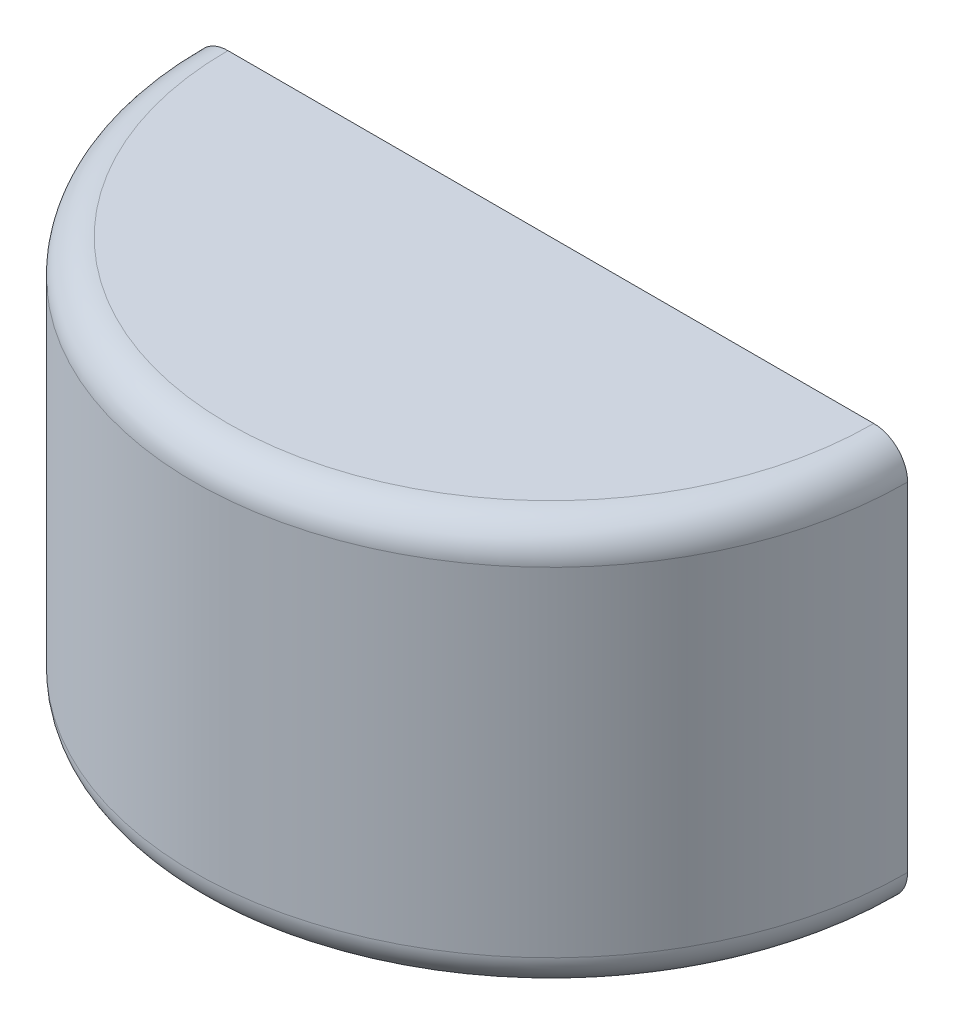
from build123d import *

# Parameters (mm, degrees)
SKETCH1_W      = 133.985
SKETCH1_H      = 152.4
REVOLVE1_ANGLE = 180
FILLET1_R      = 12.7


with BuildPart() as part:
    # Sketch1 → Revolve1 (revolve)
    with BuildSketch(Plane.XY):
        with Locations((-66.9925, 76.2)):
            Rectangle(SKETCH1_W, SKETCH1_H)
    revolve(axis=Axis((0, 0, 0), (0, 1, 0)), revolution_arc=REVOLVE1_ANGLE)

    # Fillet1
    fillet1_edges = [part.edges().sort_by_distance(p)[0] for p in [
        (0, 0, 133.985),
        (0, 152.4, 133.985),
    ]]
    fillet(fillet1_edges, radius=FILLET1_R)


solid = part.part
